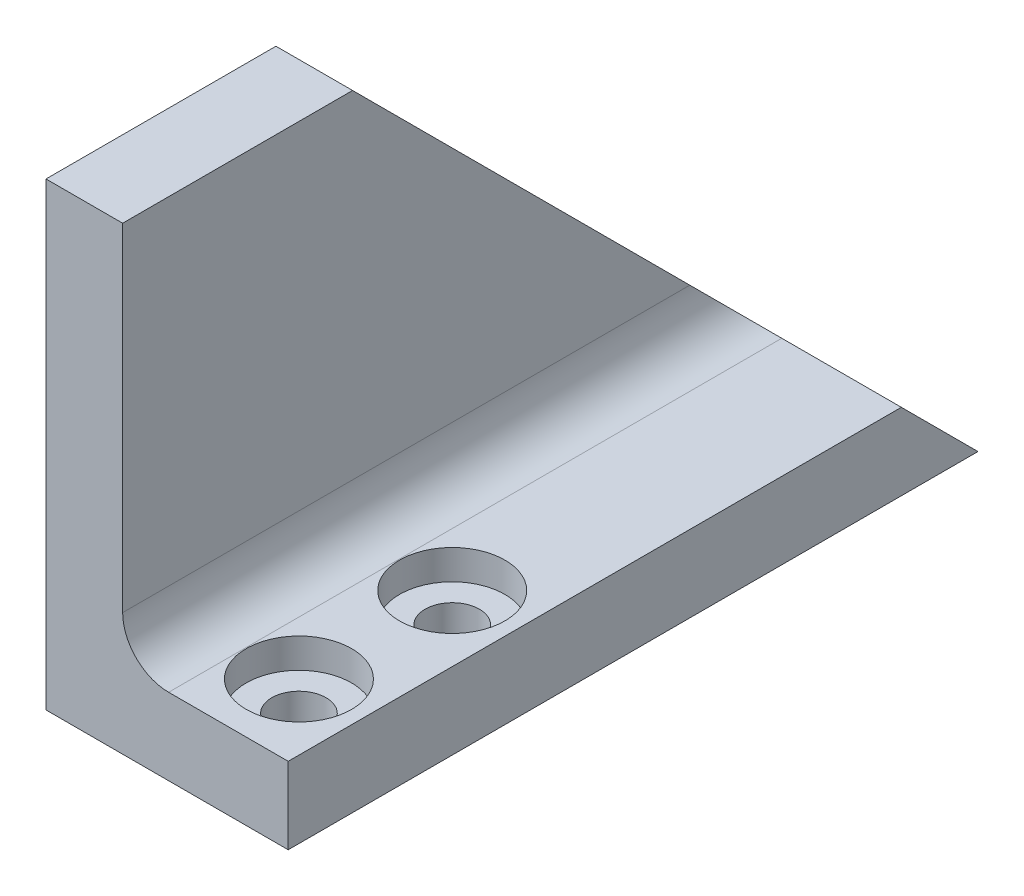
from build123d import *

# Parameters (mm, degrees)
SKETCH2_W                                      = 19.05
SKETCH2_H                                      = 57.15
BOSS_EXTRUDE2_DEPTH                            = 38.1
CUT_EXTRUDE2_DEPTH                             = 20.05
SKETCH7_W                                      = 25.4
SKETCH7_H                                      = 63.5
CUT_EXTRUDE5_DEPTH                             = 63.5
FILLET3_R                                      = 3.81
CBORE_FOR_8_BUTTON_HEAD_CAP_SCREW1_D           = 4.4958
CBORE_FOR_8_BUTTON_HEAD_CAP_SCREW1_CBORE_D     = 8.73252
CBORE_FOR_8_BUTTON_HEAD_CAP_SCREW1_CBORE_DEPTH = 2.4638
BOSS_EXTRUDE3_DEPTH                            = 1.016


with BuildPart() as part:
    # Sketch2 → Boss-Extrude2 (new body)
    with BuildSketch(Plane(origin=(0, 0, 0), x_dir=(1, 0, 0), z_dir=(0, 1, 0))):
        Rectangle(SKETCH2_W, SKETCH2_H)
    extrude(amount=BOSS_EXTRUDE2_DEPTH)

    # Sketch4 → Cut-Extrude2 (cut, through all)
    with BuildSketch(Plane(origin=(9.525, 0, 0), x_dir=(0, 0, -1), z_dir=(1, 0, 0))):
        Polygon((28.575, 0), (-9.525, 38.1), (28.575, 38.1), align=None)
    extrude(amount=-CUT_EXTRUDE2_DEPTH, mode=Mode.SUBTRACT)

    # Sketch7 → Cut-Extrude5 (cut)
    with BuildSketch(Plane.XY.offset(28.575)):
        with Locations((9.525, 38.1)):
            Rectangle(SKETCH7_W, SKETCH7_H)
    extrude(amount=-CUT_EXTRUDE5_DEPTH, mode=Mode.SUBTRACT)

    # Fillet3
    fillet3_edges = [part.edges().sort_by_distance(p)[0] for p in [
        (-3.175, 6.35, 3.175),
    ]]
    fillet(fillet3_edges, radius=FILLET3_R)

    # CBORE for #8 Button Head Cap Screw1 (through all)
    with Locations(Plane(origin=(0, 6.35, 0), x_dir=(1, 0, 0), z_dir=(0, 1, 0))):
        with Locations((5.08, -22.225), (5.08, -9.525)):
            CounterBoreHole(CBORE_FOR_8_BUTTON_HEAD_CAP_SCREW1_D / 2, CBORE_FOR_8_BUTTON_HEAD_CAP_SCREW1_CBORE_D / 2, CBORE_FOR_8_BUTTON_HEAD_CAP_SCREW1_CBORE_DEPTH)

    # Sketch12 → Boss-Extrude3 (add)
    with BuildSketch(Plane(origin=(9.525, 0, 0), x_dir=(0, 0, -1), z_dir=(1, 0, 0))):
        Polygon((28.575, 0), (22.225, 6.35), (-28.575, 6.35), (-28.575, 0), align=None)
    extrude(amount=BOSS_EXTRUDE3_DEPTH)


solid = part.part
